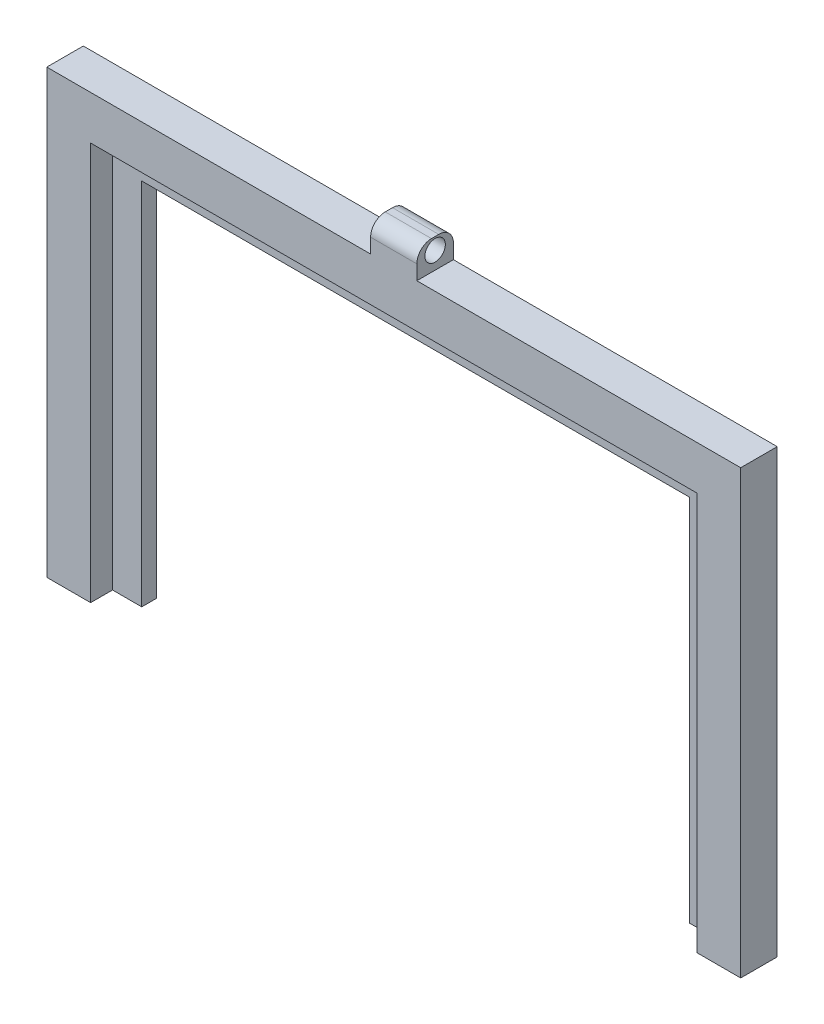
from build123d import *

# Parameters (mm, degrees)
BOSS_EXTRUDE1_DEPTH = 2
BOSS_EXTRUDE2_DEPTH = 5
SKETCH2_R           = 1.4
CUT_EXTRUDE1_DEPTH  = 8
FILLET1_R           = 2


with BuildPart() as part:
    # Sketch1 → Boss-Extrude1 (new body)
    with BuildSketch(Plane.XY):
        Polygon((-38.709801473, -35.46512078), (-34.709801473, -35.46512078), (-34.709801473, 15.03487922), (40.290198527, 15.03487922), (40.290198527, -35.46512078), (44.290198527, -35.46512078), (44.290198527, 19.03487922), (-38.709801473, 19.03487922), align=None)
    extrude(amount=BOSS_EXTRUDE1_DEPTH)

    # Sketch1_4 → Boss-Extrude2 (add)
    with BuildSketch(Plane.XY):
        Polygon((-44.709801473, -35.46512078), (-38.709801473, -35.46512078), (-38.709801473, 19.03487922), (44.290198527, 19.03487922), (44.290198527, -35.46512078), (50.290198527, -35.46512078), (50.290198527, 25.03487922), (5.955198527, 25.03487922), (5.955198527, 29.03487922), (-0.374801473, 29.03487922), (-0.374801473, 25.03487922), (-44.709801473, 25.03487922), align=None)
    extrude(amount=BOSS_EXTRUDE2_DEPTH)

    # Sketch2 → Cut-Extrude1 (cut)
    with BuildSketch(Plane(origin=(5.955198527, 0, 0), x_dir=(0, 0, -1), z_dir=(1, 0, 0))):
        with Locations((-2.5, 27.39487922)):
            Circle(SKETCH2_R)
    extrude(amount=-CUT_EXTRUDE1_DEPTH, mode=Mode.SUBTRACT)

    # Fillet1
    fillet1_edges = [part.edges().sort_by_distance(p)[0] for p in [
        (2.790198527, 29.03487922, 0),
        (2.790198527, 29.03487922, 5),
    ]]
    fillet(fillet1_edges, radius=FILLET1_R)


solid = part.part
